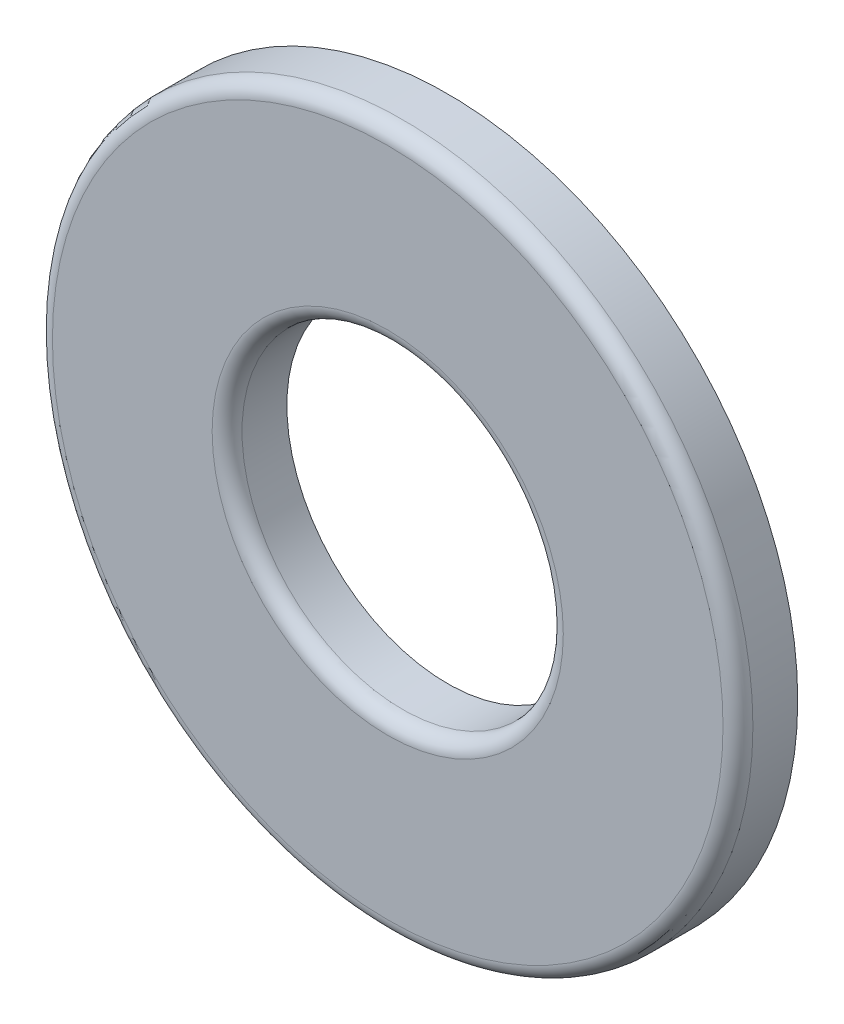
from build123d import *

# Parameters (mm, degrees)
SKETCH3_R                = 4.7625
SKETCH3_R_2              = 2.1844
BOSS_EXTRUDE1_DEPTH      = 0.4064
BOSS_EXTRUDE1_DEPTH_BACK = 0.4064
FILLET1_R                = 0.2032


with BuildPart() as part:
    # Sketch3 → Boss-Extrude1 (new body, two sides)
    with BuildSketch(Plane.XY) as boss_extrude1_sk:
        Circle(SKETCH3_R)
        Circle(SKETCH3_R_2, mode=Mode.SUBTRACT)
    extrude(amount=BOSS_EXTRUDE1_DEPTH)
    extrude(boss_extrude1_sk.sketch, amount=-BOSS_EXTRUDE1_DEPTH_BACK)

    # Fillet1
    fillet1_edges = [part.edges().sort_by_distance(p)[0] for p in [
        (-4.7625, 0, 0.4064),
        (-2.1844, 0, 0.4064),
    ]]
    fillet(fillet1_edges, radius=FILLET1_R)


solid = part.part
